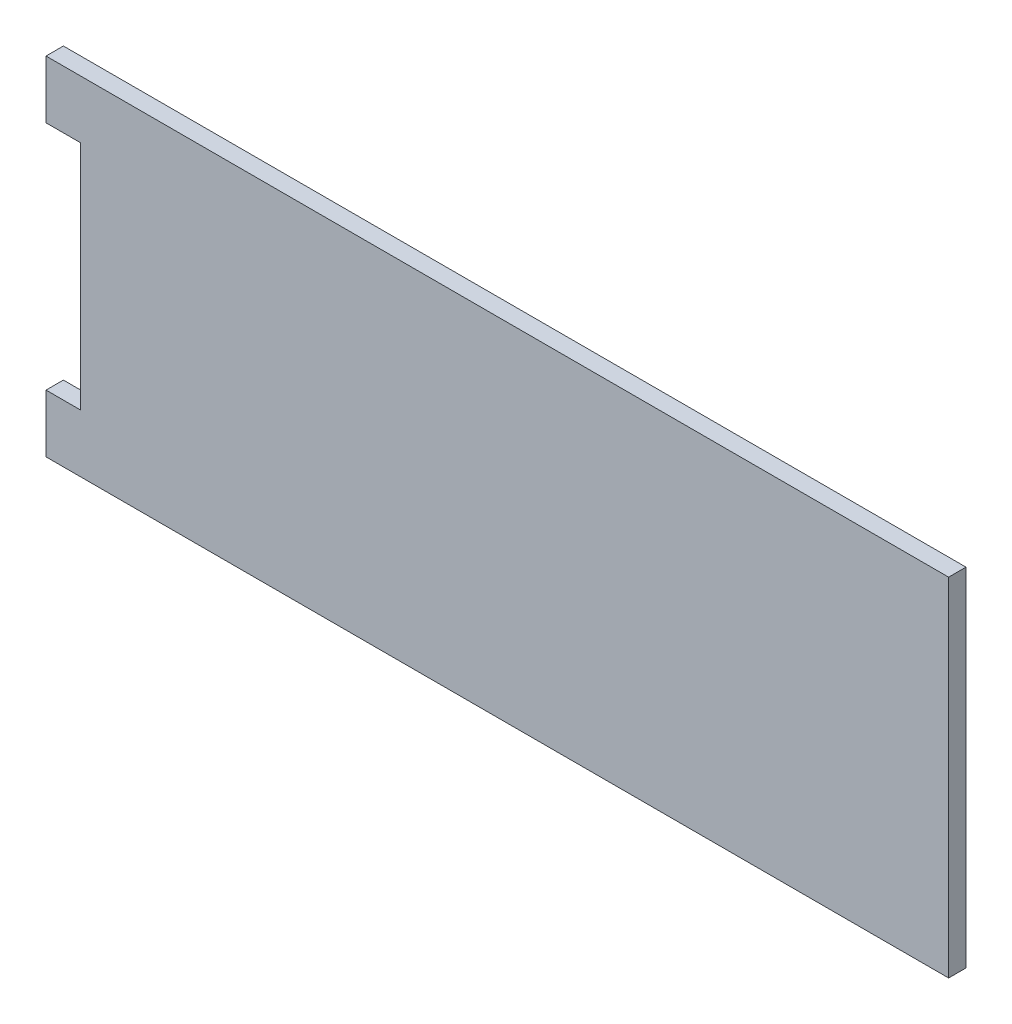
from build123d import *

# Parameters (mm, degrees)
BOSS_EXTRU_1_DEPTH = 3


with BuildPart() as part:
    # Esquisse1 → Boss.-Extru.1 (new body)
    with BuildSketch(Plane.XY):
        Polygon((-111.587814085, 105.992647465), (38.412185915, 105.992647465), (38.412185915, 45.992647465), (-111.587814085, 45.992647465), (-117.587814085, 45.992647465), (-117.587814085, 55.992647465), (-111.587814085, 55.992647465), (-111.587814085, 95.992647465), (-117.587814085, 95.992647465), (-117.587814085, 105.992647465), align=None)
    extrude(amount=BOSS_EXTRU_1_DEPTH)


solid = part.part
